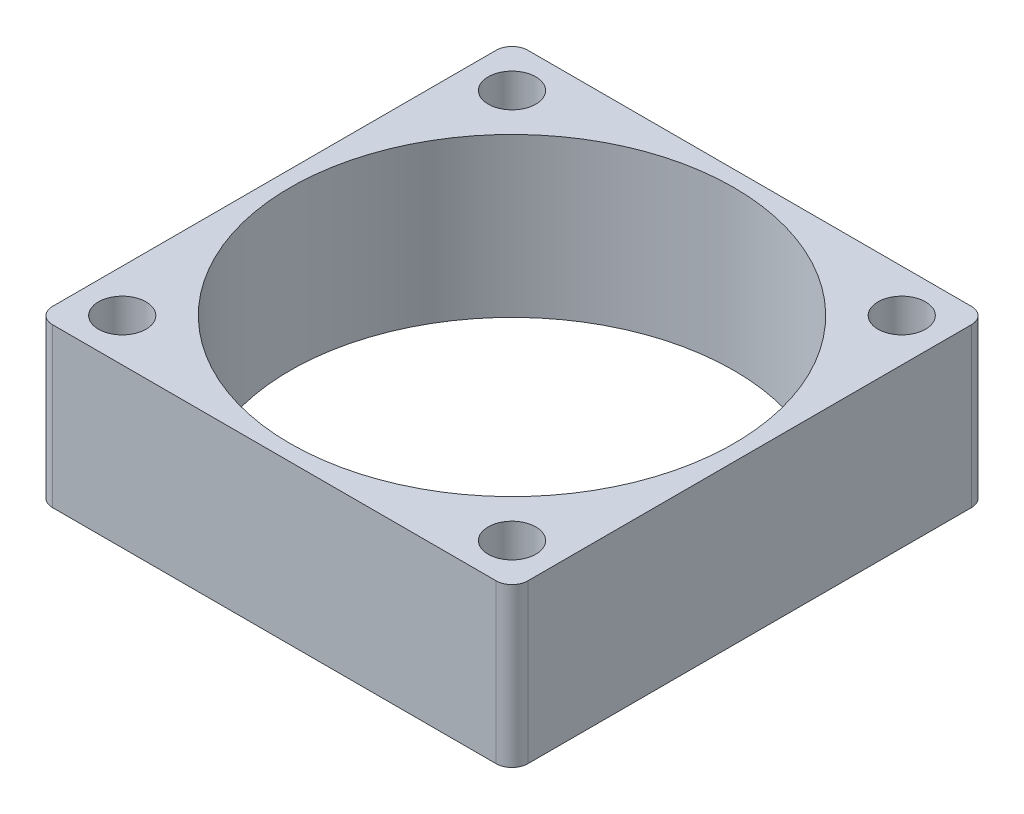
from build123d import *

# Parameters (mm, degrees)
SKETCH_1_W          = 30
SKETCH_1_H          = 30
EXTRUDE_1_DEPTH     = 10
SKETCH_2_R          = 1.5
CUT_EXTRUDE_1_DEPTH = 11
FILLET_1_R          = 1
SKETCH_3_R          = 14
CUT_EXTRUDE_2_DEPTH = 11


with BuildPart() as part:
    # 草图1 → 凸台-拉伸1 (new body)
    with BuildSketch(Plane(origin=(0, 0, 0), x_dir=(1, 0, 0), z_dir=(0, 1, 0))):
        Rectangle(SKETCH_1_W, SKETCH_1_H)
    extrude(amount=EXTRUDE_1_DEPTH)

    # 草图2 → 切除-拉伸1 (cut, through all)
    with BuildSketch(Plane(origin=(0, 10, 0), x_dir=(1, 0, 0), z_dir=(0, 1, 0))):
        with Locations((-12.3, 12.3)):
            Circle(SKETCH_2_R)
        with Locations((12.3, 12.3)):
            Circle(SKETCH_2_R)
        with Locations((-12.3, -12.3)):
            Circle(SKETCH_2_R)
        with Locations((12.3, -12.3)):
            Circle(SKETCH_2_R)
    extrude(amount=-CUT_EXTRUDE_1_DEPTH, mode=Mode.SUBTRACT)

    # 圆角1
    fillet_1_edges = [part.edges().sort_by_distance(p)[0] for p in [
        (15, 5, 15),
        (-15, 5, 15),
        (-15, 5, -15),
        (15, 5, -15),
    ]]
    fillet(fillet_1_edges, radius=FILLET_1_R)

    # 草图3 → 切除-拉伸2 (cut, through all)
    with BuildSketch(Plane(origin=(0, 10, 0), x_dir=(1, 0, 0), z_dir=(0, 1, 0))):
        Circle(SKETCH_3_R)
    extrude(amount=-CUT_EXTRUDE_2_DEPTH, mode=Mode.SUBTRACT)


solid = part.part
